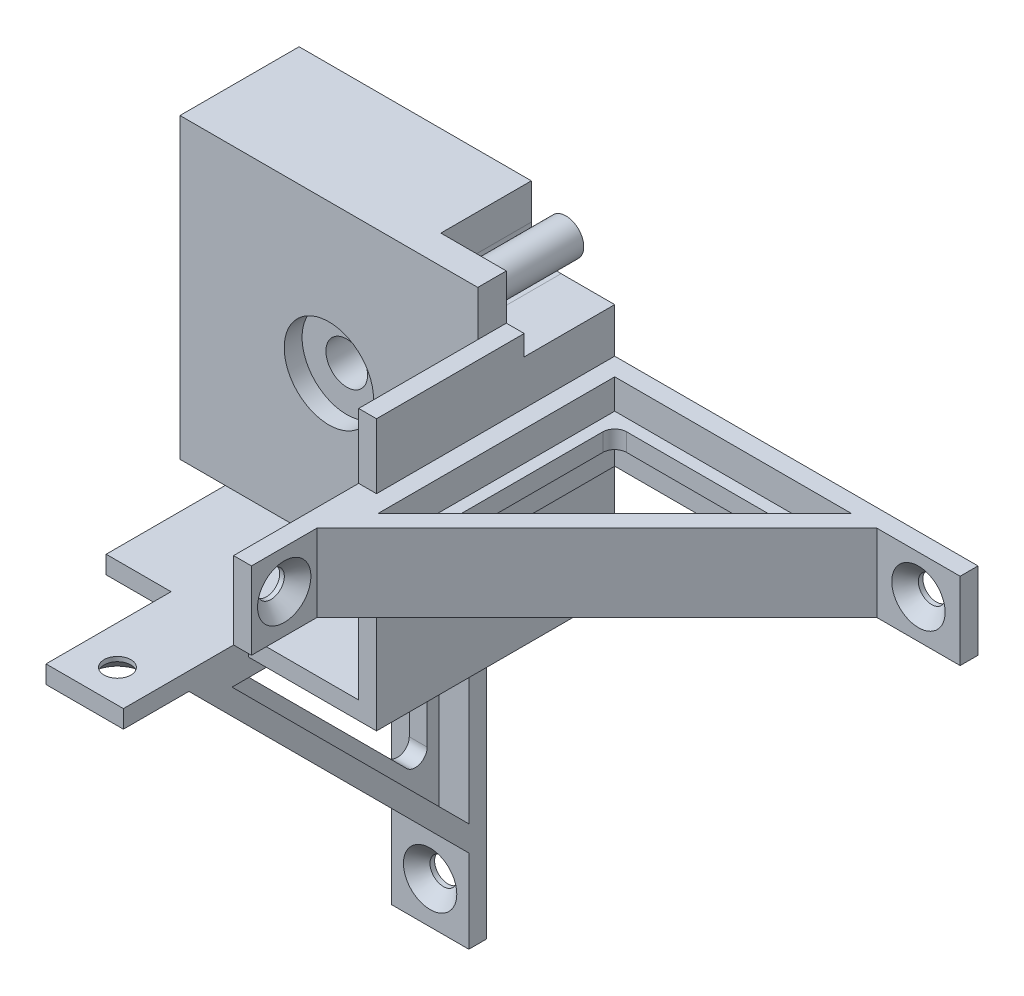
from build123d import *

# Parameters (mm, degrees)
CROQUIS2_W                                           = 50
CROQUIS2_H                                           = 50
CROQUIS2_R                                           = 3.5
SALIENTE_EXTRUIR2_DEPTH                              = 20
CROQUIS3_R                                           = 7.5
CORTAR_EXTRUIR1_DEPTH                                = 3
SALIENTE_EXTRUIR3_DEPTH                              = 40
SALIENTE_EXTRUIR4_DEPTH                              = 2.65
CORTAR_EXTRUIR2_START                                = -2
CORTAR_EXTRUIR2_DEPTH                                = 5
CORTAR_EXTRUIR5_START                                = -2.65
CORTAR_EXTRUIR5_DEPTH                                = 2.65
SALIENTE_EXTRUIR5_DEPTH                              = 44.75
CROQUIS13_R                                          = 3
CORTAR_EXTRUIR6_DEPTH                                = 15.2
SALIENTE_EXTRUIR6_START                              = -21.5
SALIENTE_EXTRUIR6_DEPTH                              = 13
SALIENTE_EXTRUIR7_START                              = -5
SALIENTE_EXTRUIR7_DEPTH                              = 3
REDONDEO1_R                                          = 2
CROQUIS17_R                                          = 2
CORTAR_EXTRUIR7_DEPTH                                = 3
CROQUIS18_R                                          = 2
CORTAR_EXTRUIR8_DEPTH                                = 3
REFRENTADO_PARA_TORNILLO_TAP_N_CON_CABEZ_D           = 4.5
REFRENTADO_PARA_TORNILLO_TAP_N_CON_CABEZ_CSINK_D     = 8.96
REFRENTADO_PARA_TORNILLO_TAP_N_CON_CABEZ_CSINK_ANGLE = 90
REDONDEO1_OF_SIMETR_A3_R                             = 2


with BuildPart() as part:
    # Croquis2 → Saliente-Extruir2 (new body)
    with BuildSketch(Plane.XY):
        Rectangle(CROQUIS2_W, CROQUIS2_H)
        Circle(CROQUIS2_R, mode=Mode.SUBTRACT)
    extrude(amount=SALIENTE_EXTRUIR2_DEPTH)

    # Croquis3 → Cortar-Extruir1 (cut)
    with BuildSketch(Plane.XY.offset(20)):
        Circle(CROQUIS3_R)
    extrude(amount=-CORTAR_EXTRUIR1_DEPTH, mode=Mode.SUBTRACT)

    # Croquis4 → Saliente-Extruir3 (add)
    with BuildSketch(Plane(origin=(0, 0, 0), x_dir=(-1, 0, 0), z_dir=(0, 0, -1))):
        Polygon((-25, -25), (-25, 17.4), (-28, 17.4), (-28, -28), (17.4, -28), (17.4, -25), align=None)
    extrude(amount=-SALIENTE_EXTRUIR3_DEPTH)

    # Croquis5 → Saliente-Extruir4 (add)
    with BuildSketch(Plane(origin=(0, 17.4, 0), x_dir=(1, 0, 0), z_dir=(0, 1, 0))):
        Polygon((25, 0), (51, 0), (25, -25), align=None)
    saliente_extruir4 = extrude(amount=-SALIENTE_EXTRUIR4_DEPTH)

    # Croquis6 → Cortar-Extruir2 (cut)
    with BuildSketch(Plane.XZ.offset(-14.75).offset(CORTAR_EXTRUIR2_START)):
        Polygon((44.824955825, 4.550258722), (30.300169567, 18.516399355), (26.037550962, 14.083276006), (40.56233722, 0.117135373), align=None)
    cortar_extruir2 = extrude(amount=CORTAR_EXTRUIR2_DEPTH, mode=Mode.SUBTRACT)

    # Simetría2: Saliente-Extruir4, Cortar-Extruir2 across plane
    add(saliente_extruir4.mirror(Plane(origin=(0, 0, 0), x_dir=(0, 0, 1), z_dir=(0.707106781, 0.707106781, 0))))
    add(cortar_extruir2.mirror(Plane(origin=(0, 0, 0), x_dir=(0, 0, 1), z_dir=(0.707106781, 0.707106781, 0))), mode=Mode.SUBTRACT)

    # Croquis11 → Cortar-Extruir5 (cut)
    with BuildSketch(Plane.XZ.offset(-14.75).offset(CORTAR_EXTRUIR5_START)):
        Polygon((28, 0), (51, 0), (28, 22.115384615), align=None)
    extrude(amount=CORTAR_EXTRUIR5_DEPTH, mode=Mode.SUBTRACT)

    # Croquis14 → Saliente-Extruir5 (add)
    with BuildSketch(Plane.XZ.offset(-16.75)):
        Polygon((26.037550962, 14.083276006), (28, 12.196305777), (28, 16.124223005), align=None)
    extrude(amount=SALIENTE_EXTRUIR5_DEPTH)

    # Croquis13 → Cortar-Extruir6 (cut)
    with BuildSketch(Plane(origin=(0, 0, 0), x_dir=(-1, 0, 0), z_dir=(0, 0, -1))):
        with BuildLine():
            Line((-25, 25), (-14, 25))
            Line((-14, 25), (-14, 19))
            ThreePointArc((-14, 19), (-15.464466094, 15.464466094), (-19, 14))
            Line((-19, 14), (-25, 14))
            Line((-25, 14), (-28, 14))
            Line((-28, 14), (-28, 17.4))
            Line((-28, 17.4), (-25, 17.4))
            Line((-25, 17.4), (-25, 25))
        make_face()
        with Locations((-19.802765158, 19.802765158)):
            Circle(CROQUIS13_R, mode=Mode.SUBTRACT)
    extrude(amount=-CORTAR_EXTRUIR6_DEPTH, mode=Mode.SUBTRACT)

    # Croquis15 → Saliente-Extruir6 (add)
    with BuildSketch(Plane.XZ.offset(28).offset(SALIENTE_EXTRUIR6_START)):
        Polygon((28, 0), (78, 0), (89, 0), (89, 3), (75, 3), (28, 50), (28, 61), (25, 61), (25, 40), (28, 40), align=None)
        Polygon((31, 42.757359313), (70.757359313, 3), (31, 3), align=None, mode=Mode.SUBTRACT)
    saliente_extruir6 = extrude(amount=-SALIENTE_EXTRUIR6_DEPTH)

    # Croquis16 → Saliente-Extruir7 (add)
    with BuildSketch(Plane.XZ.offset(6.5).offset(SALIENTE_EXTRUIR7_START)):
        Polygon((31, 3), (70.757359313, 3), (31, 42.757359313), align=None)
        Polygon((33, 5), (65.928932188, 5), (33, 37.928932188), align=None, mode=Mode.SUBTRACT)
    saliente_extruir7 = extrude(amount=-SALIENTE_EXTRUIR7_DEPTH)

    # Redondeo1
    redondeo1_edges = [part.edges().sort_by_distance(p)[0] for p in [
        (33, 0, 37.928932188),
        (65.928932188, 0, 5),
        (33, 0, 5),
    ]]
    fillet(redondeo1_edges, radius=REDONDEO1_R)

    # Croquis17 → Cortar-Extruir7 (cut)
    with BuildSketch(Plane.XY.offset(3)):
        with Locations((82, 0)):
            Circle(CROQUIS17_R)
    cortar_extruir7 = extrude(amount=-CORTAR_EXTRUIR7_DEPTH, mode=Mode.SUBTRACT)

    # Croquis18 → Cortar-Extruir8 (cut)
    with BuildSketch(Plane(origin=(28, 0, 0), x_dir=(0, 0, -1), z_dir=(1, 0, 0))):
        with Locations((-55.5, 0)):
            Circle(CROQUIS18_R)
    cortar_extruir8 = extrude(amount=-CORTAR_EXTRUIR8_DEPTH, mode=Mode.SUBTRACT)

    # Refrentado para tornillo tap_n con cabez (through all)
    with Locations(Plane(origin=(28, 0, 0), x_dir=(0, 0, -1), z_dir=(1, 0, 0))):
        with Locations((-55.5, 0)):
            refrentado_para_tornillo_tap_n_con_cabez = CounterSinkHole(REFRENTADO_PARA_TORNILLO_TAP_N_CON_CABEZ_D / 2, REFRENTADO_PARA_TORNILLO_TAP_N_CON_CABEZ_CSINK_D / 2, counter_sink_angle=REFRENTADO_PARA_TORNILLO_TAP_N_CON_CABEZ_CSINK_ANGLE)

    # Croquis22 → Refrentado para tornillo tap_n con c 2 (revolve, cut)
    with BuildSketch(Plane(origin=(82, 0, 3), x_dir=(0, -1, 0), z_dir=(1, 0, 0))):
        Polygon((0, 0), (0, 3), (2.25, 3), (2.25, 2.23), (4.48, 0), align=None)
    refrentado_para_tornillo_tap_n_con_c_2 = revolve(axis=Axis((82, 0, 9.35), (0, 0, -1)), mode=Mode.SUBTRACT)

    # Simetría3: Saliente-Extruir6, Saliente-Extruir7, Cortar-Extruir7, Cortar-Extruir8, Refrentado para tornillo tap_n con cabez, Refrentado para tornillo tap_n con c 2 across plane
    add(saliente_extruir6.mirror(Plane(origin=(0, 0, 0), x_dir=(0, 0, 1), z_dir=(0.707106781, 0.707106781, 0))))
    add(saliente_extruir7.mirror(Plane(origin=(0, 0, 0), x_dir=(0, 0, 1), z_dir=(0.707106781, 0.707106781, 0))))
    add(cortar_extruir7.mirror(Plane(origin=(0, 0, 0), x_dir=(0, 0, 1), z_dir=(0.707106781, 0.707106781, 0))), mode=Mode.SUBTRACT)
    add(cortar_extruir8.mirror(Plane(origin=(0, 0, 0), x_dir=(0, 0, 1), z_dir=(0.707106781, 0.707106781, 0))), mode=Mode.SUBTRACT)
    add(refrentado_para_tornillo_tap_n_con_cabez.mirror(Plane(origin=(0, 0, 0), x_dir=(0, 0, 1), z_dir=(0.707106781, 0.707106781, 0))), mode=Mode.SUBTRACT)
    add(refrentado_para_tornillo_tap_n_con_c_2.mirror(Plane(origin=(0, 0, 0), x_dir=(0, 0, 1), z_dir=(0.707106781, 0.707106781, 0))), mode=Mode.SUBTRACT)

    # Redondeo1 of Simetría3
    redondeo1_of_simetr_a3_edges = [part.edges().sort_by_distance(p)[0] for p in [
        (0, -33, 37.928932188),
        (0, -65.928932188, 5),
        (0, -33, 5),
    ]]
    fillet(redondeo1_of_simetr_a3_edges, radius=REDONDEO1_OF_SIMETR_A3_R)


solid = part.part
